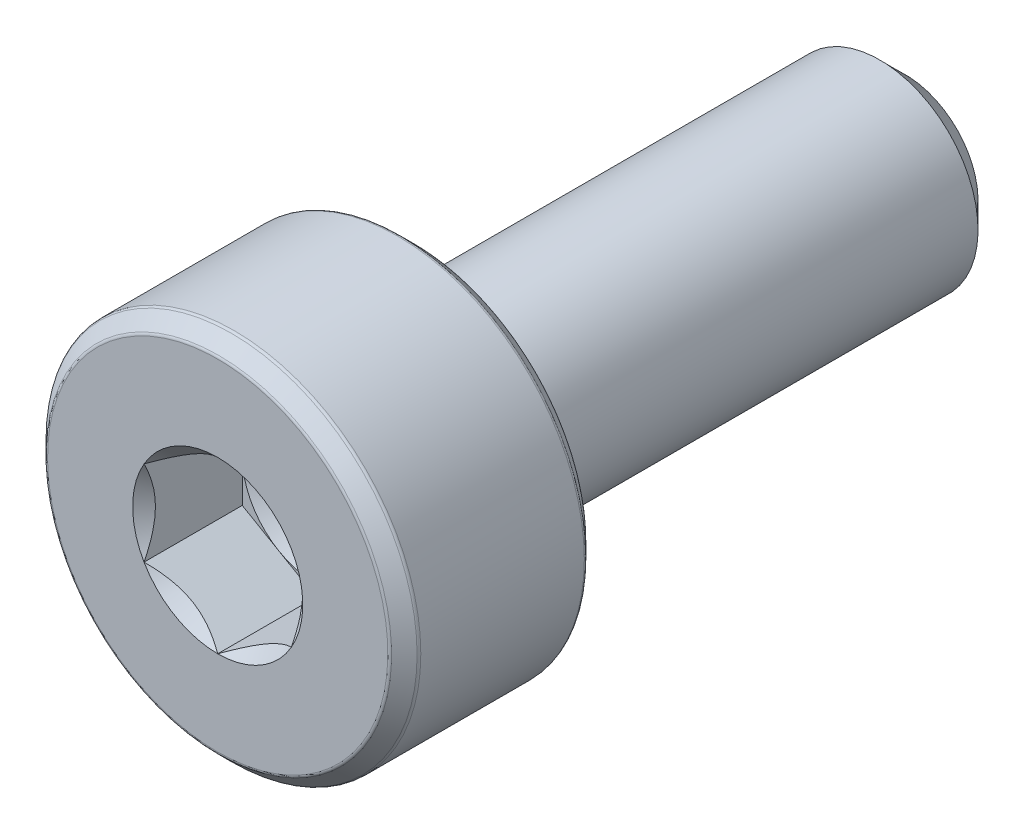
from build123d import *

# Parameters (mm, degrees)
CUT_EXTRUDE1_DEPTH = 1


with BuildPart() as part:
    # Sketch3 → Revolve1 (revolve)
    with BuildSketch(Plane(origin=(0, 0, 0), x_dir=(0, 0, -1), z_dir=(1, 0, 0)), mode=Mode.PRIVATE) as revolve1_sk:
        with BuildLine():
            Line((-3.5, 1.732259885), (-3.5, 0.75))
            Line((-3.5, 0.75), (-2.5, 0.75))
            Line((-2.5, 0.75), (-2.5, 0))
            Line((-2.5, 0), (3.5, 0))
            Line((3.5, 0), (3.5, 0.740192379))
            Line((3.5, 0.740192379), (3.240192379, 1))
            Line((3.240192379, 1), (-1.5, 1))
            Line((-1.5, 1), (-1.5, 1.732259885))
            ThreePointArc((-1.5, 1.732259885), (-1.502892578, 1.746801855), (-1.511129942, 1.759129942))
            Line((-1.511129942, 1.759129942), (-1.640870058, 1.888870058))
            ThreePointArc((-1.640870058, 1.888870058), (-1.653198145, 1.897107422), (-1.667740115, 1.9))
            Line((-1.667740115, 1.9), (-3.332259885, 1.9))
            ThreePointArc((-3.332259885, 1.9), (-3.346801855, 1.897107422), (-3.359129942, 1.888870058))
            Line((-3.359129942, 1.888870058), (-3.488870058, 1.759129942))
            ThreePointArc((-3.488870058, 1.759129942), (-3.497107422, 1.746801855), (-3.5, 1.732259885))
        make_face()
    revolve(revolve1_sk.sketch.rotate(Axis((0, 0, 3.5), (0, 0, -1)), 180), axis=Axis((0, 0, 3.5), (0, 0, -1)))

    # Sketch4 → Cut-Extrude1 (cut)
    with BuildSketch(Plane.XY.offset(3.5)):
        Polygon((0, 0.866025404), (-0.75, 0.433012702), (-0.75, -0.433012702), (0, -0.866025404), (0.75, -0.433012702), (0.75, 0.433012702), align=None)
    extrude(amount=-CUT_EXTRUDE1_DEPTH, mode=Mode.SUBTRACT)

    # Cut-Extrude2 cone 1 section (through the dimple's axis) → Cut-Extrude2 (revolve, cut)
    with BuildSketch(Plane(origin=(0, 0, 3.5), x_dir=(0, -1, 0), z_dir=(1, 0, 0))):
        Polygon((0, 0), (0.866025404, 0), (0, 0.866025404), align=None)
    revolve(axis=Axis((0, 0, 3.5), (0, 0, -1)), mode=Mode.SUBTRACT)

    # Cut-Extrude3 cone 1 section (through the dimple's axis) → Cut-Extrude3 (revolve, cut)
    with BuildSketch(Plane(origin=(0, 0, 2.5), x_dir=(0, -1, 0), z_dir=(1, 0, 0))):
        Polygon((0, 0), (0.75, 0), (0, 0.433012702), align=None)
    revolve(axis=Axis((0, 0, 2.5), (0, 0, -1)), mode=Mode.SUBTRACT)


solid = part.part
